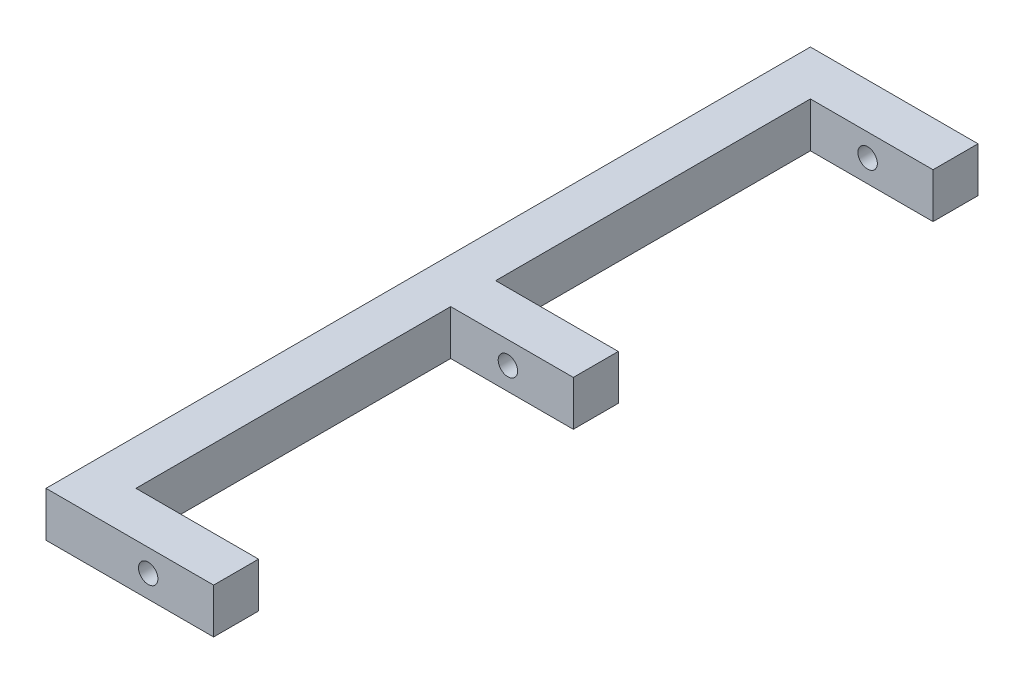
from build123d import *

# Parameters (mm, degrees)
ESQUISSE1_W      = 22
ESQUISSE1_H      = 22
EXTRUSION1_DEPTH = 374
ESQUISSE2_W      = 22
ESQUISSE2_H      = 22
EXTRUSION2_DEPTH = 60
ESQUISSE3_R      = 4.75
EXTRUSION3_DEPTH = 374


with BuildPart() as part:
    # Esquisse1 → Extrusion1 (new body)
    with BuildSketch(Plane.XY):
        with Locations((11, 11)):
            Rectangle(ESQUISSE1_W, ESQUISSE1_H)
    extrude(amount=EXTRUSION1_DEPTH)

    # Esquisse2 → Extrusion2 (add)
    with BuildSketch(Plane(origin=(22, 0, 0), x_dir=(0, 0, -1), z_dir=(1, 0, 0))):
        with Locations((-11, 11)):
            Rectangle(ESQUISSE2_W, ESQUISSE2_H)
        with Locations((-363, 11)):
            Rectangle(ESQUISSE2_W, ESQUISSE2_H)
        with Locations((-187, 11)):
            Rectangle(ESQUISSE2_W, ESQUISSE2_H)
    extrude(amount=EXTRUSION2_DEPTH)

    # Esquisse3 → Extrusion3 (cut)
    with BuildSketch(Plane.XY.offset(374)):
        with Locations((50, 11)):
            Circle(ESQUISSE3_R)
    extrude(amount=-EXTRUSION3_DEPTH, mode=Mode.SUBTRACT)


solid = part.part
